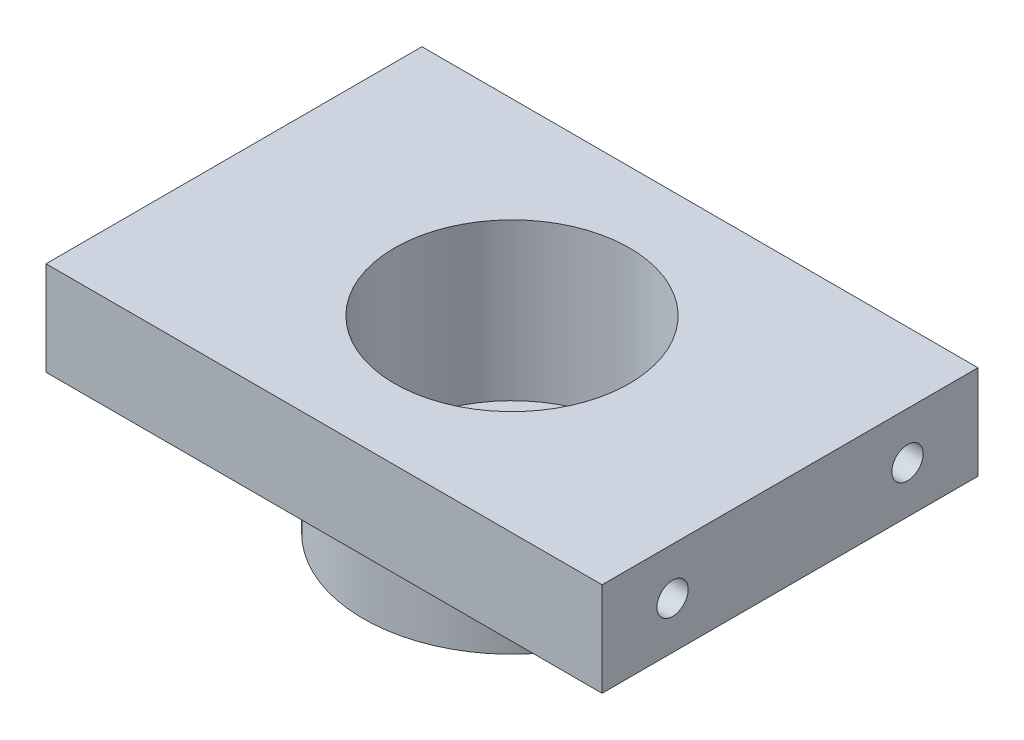
from build123d import *

# Parameters (mm, degrees)
ESQUISSE4_R           = 1.5
EXTRUSION3_DEPTH      = 25
ESQUISSE5_OUTSIDE_W   = 153.718
ESQUISSE5_OUTSIDE_H   = 153.718
ESQUISSE5_OUTSIDE_W_2 = 71
ESQUISSE5_OUTSIDE_H_2 = 48
EXTRUSION4_DEPTH      = 13
ESQUISSE6_R           = 2
EXTRUSION5_DEPTH      = 10
ESQUISSE7_R           = 2
EXTRUSION6_DEPTH      = 10


with BuildPart() as part:
    # Esquisse1 → Révolution1 (revolve)
    with BuildSketch(Plane.XY):
        Polygon((19, -12), (59, -12), (59, 0), (15, 0), (15, -20), (9, -20), (9, -24), (19, -24), align=None)
    revolve(axis=Axis((0, 0, 0), (0, -1, 0)))

    # Esquisse4 → Extrusion3 (cut, through all)
    with BuildSketch(Plane.XZ.offset(24)):
        with Locations((0, 13)):
            Circle(ESQUISSE4_R)
        with Locations((13, 0)):
            Circle(ESQUISSE4_R)
        with Locations((0, -13)):
            Circle(ESQUISSE4_R)
        with Locations((-13, 0)):
            Circle(ESQUISSE4_R)
    extrude(amount=-EXTRUSION3_DEPTH, mode=Mode.SUBTRACT)

    # Esquisse5 outside → Extrusion4 (cut, through all)
    with BuildSketch(Plane.XZ.offset(12)):
        Rectangle(ESQUISSE5_OUTSIDE_W, ESQUISSE5_OUTSIDE_H)
        Rectangle(ESQUISSE5_OUTSIDE_W_2, ESQUISSE5_OUTSIDE_H_2, mode=Mode.SUBTRACT)
    extrude(amount=-EXTRUSION4_DEPTH, mode=Mode.SUBTRACT)

    # Esquisse6 → Extrusion5 (cut)
    with BuildSketch(Plane(origin=(35.5, 0, 0), x_dir=(0, 0, -1), z_dir=(1, 0, 0))):
        with Locations((-15, -6)):
            Circle(ESQUISSE6_R)
        with Locations((15, -6)):
            Circle(ESQUISSE6_R)
    extrude(amount=-EXTRUSION5_DEPTH, mode=Mode.SUBTRACT)

    # Esquisse7 → Extrusion6 (cut)
    with BuildSketch(Plane.ZY.offset(35.5)):
        with Locations((15, -6)):
            Circle(ESQUISSE7_R)
        with Locations((-15, -6)):
            Circle(ESQUISSE7_R)
    extrude(amount=-EXTRUSION6_DEPTH, mode=Mode.SUBTRACT)


solid = part.part
